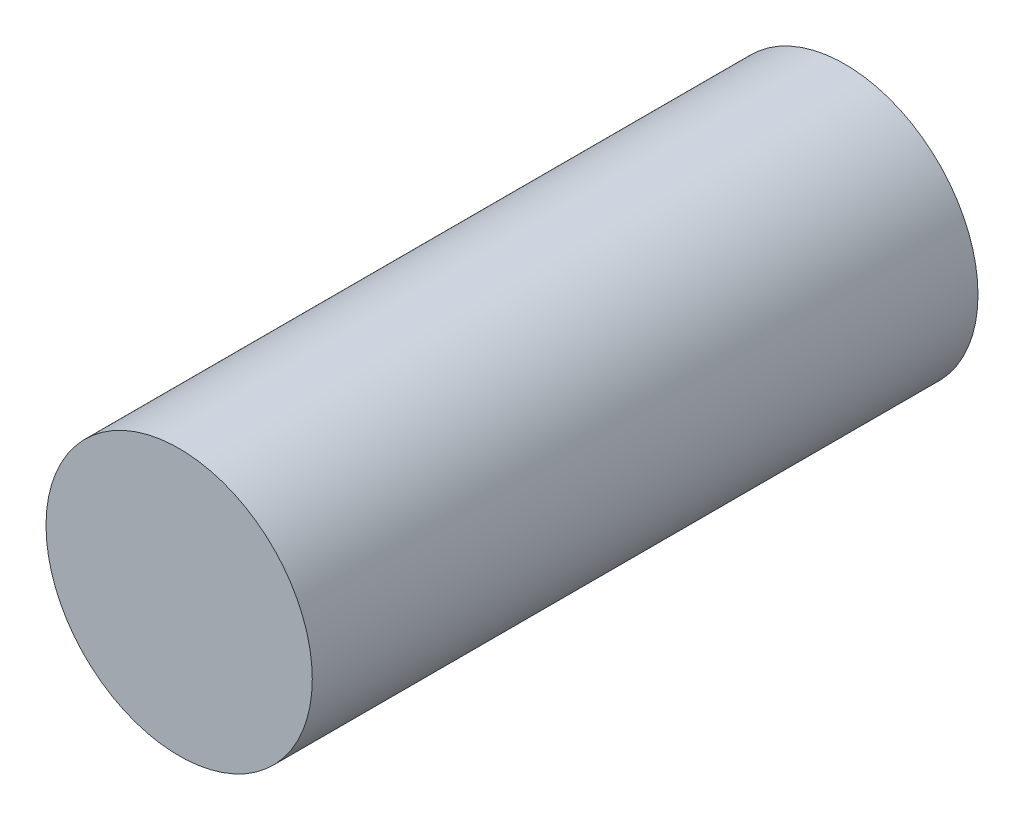
from build123d import *

# Parameters (mm, degrees)
SKETCH1_R           = 4
BOSS_EXTRUDE1_DEPTH = 20


with BuildPart() as part:
    # Sketch1 → Boss-Extrude1 (new body)
    with BuildSketch(Plane.XY):
        Circle(SKETCH1_R)
    extrude(amount=BOSS_EXTRUDE1_DEPTH)


solid = part.part
